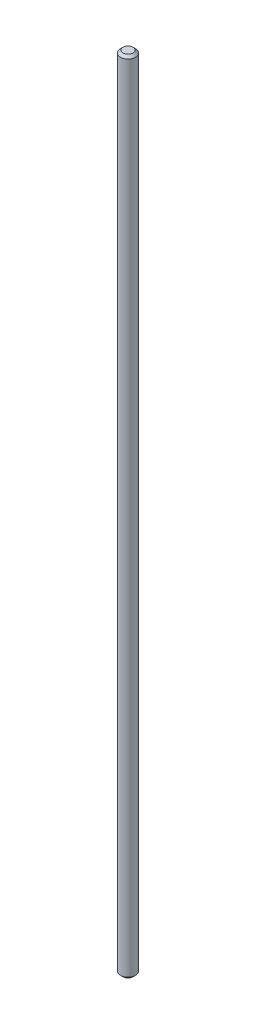
from build123d import *

# Parameters (mm, degrees)
SKETCH_1_R      = 3
EXTRUDE_1_DEPTH = 320
CHAMFER_1_SIZE  = 1
CHAMFER_2_SIZE  = 1


with BuildPart() as part:
    # Эскиз1 → Бобышка-Вытянуть1 (new body)
    with BuildSketch(Plane(origin=(0, 0, 0), x_dir=(1, 0, 0), z_dir=(0, 1, 0))):
        Circle(SKETCH_1_R)
    extrude(amount=EXTRUDE_1_DEPTH)

    # Фаска1
    chamfer_1_edges = [part.edges().sort_by_distance(p)[0] for p in [
        (-3, 320, 0),
    ]]
    chamfer(chamfer_1_edges, length=CHAMFER_1_SIZE)

    # Фаска2
    chamfer_2_edges = [part.edges().sort_by_distance(p)[0] for p in [
        (-3, 0, 0),
    ]]
    chamfer(chamfer_2_edges, length=CHAMFER_2_SIZE)


solid = part.part
